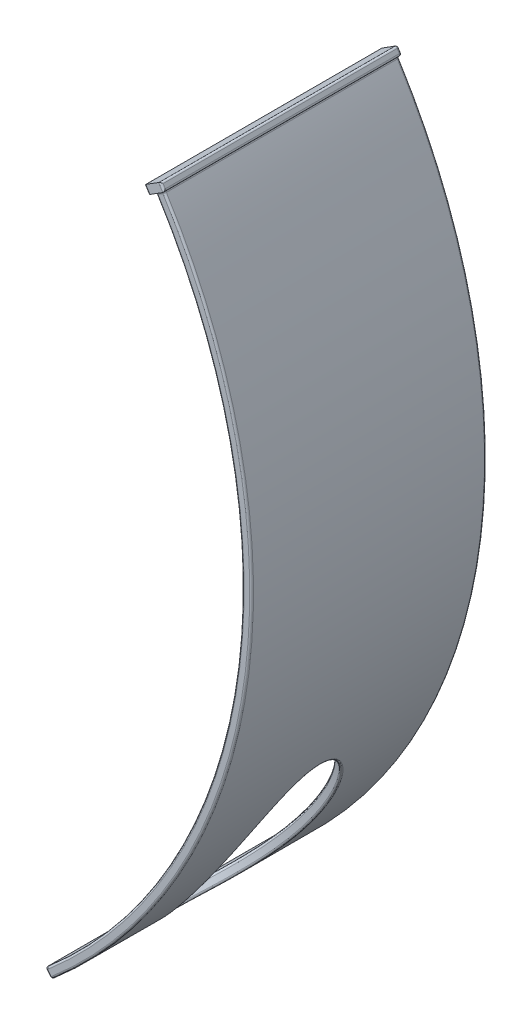
from build123d import *

# Parameters (mm, degrees)
SKETCH11_W              = 0.6
SKETCH11_H              = 15
SKETCH12_W              = 15
SKETCH12_H              = 0.6
BOSS_EXTRUDE1_DEPTH     = 0.2
SKETCH14_W              = 1.2
SKETCH14_H              = 15.2
BOSS_EXTRUDE2_DEPTH     = 0.5
SKETCH15_RX             = 7.50922571
SKETCH15_RY             = 3.403837019
CUT_EXTRUDE1_DEPTH      = 36.866449775
CUT_EXTRUDE1_DEPTH_BACK = 9.964201433
FILLET1_R               = 0.12


with BuildPart() as part:
    # Sweep1: sweep along a path in Sketch7
    with BuildLine(Plane.XY) as sweep1_path:
        ThreePointArc((12.832156868, 1.661937028), (17.974752885, -22.779601272), (5.915655903, -44.652261565))
    # Sketch11 → Sweep1 (sweep)
    with BuildSketch(Plane(origin=(0, -17.481848747, 0), x_dir=(1, 0, 0), z_dir=(0, 1, 0))):
        with Locations((18.66815125, 0)):
            Rectangle(SKETCH11_W, SKETCH11_H)
    sweep(path=sweep1_path.line)

    # Sketch12 → Boss-Extrude1 (add)
    with BuildSketch(Plane(origin=(-18.686960593, -16.10455616, 0), x_dir=(0, 0, 1), z_dir=(-0.757508036, -0.652825838, 0))):
        with Locations((0, -37.986339997)):
            Rectangle(SKETCH12_W, SKETCH12_H)
    extrude(amount=BOSS_EXTRUDE1_DEPTH)

    # Sketch14 → Boss-Extrude2 (add)
    with BuildSketch(Plane(origin=(2.905305624, -4.603278943, 0), x_dir=(0.845657103, 0.533726582, 0), z_dir=(-0.533726582, 0.845657103, 0))):
        with Locations((12.038624569, -0.1)):
            Rectangle(SKETCH14_W, SKETCH14_H)
    extrude(amount=BOSS_EXTRUDE2_DEPTH)

    # Sketch15 → Cut-Extrude1 (cut, two sides)
    with BuildSketch(Plane(origin=(24.602616496, -28.547705405, 0), x_dir=(0.757508036, 0.652825838, 0), z_dir=(-0.652825838, 0.757508036, 0))) as cut_extrude1_sk:
        with Locations(Location((-16.668993196, 0), (0, 0, 180))):
            Ellipse(SKETCH15_RX, SKETCH15_RY)
    extrude(amount=CUT_EXTRUDE1_DEPTH, mode=Mode.SUBTRACT)
    extrude(cut_extrude1_sk.sketch, amount=-CUT_EXTRUDE1_DEPTH_BACK, mode=Mode.SUBTRACT)

    # Fillet1
    fillet1_edges = [part.edges().sort_by_distance(p)[0] for p in [
        (17.974752885, -22.779601272, -7.5),
        (5.8399051, -44.717544149, -7.5),
        (6.231600603, -45.172048971, -7.5),
        (17.974752885, -22.779601272, 7.5),
        (6.231600603, -45.172048971, 7.5),
        (5.8399051, -44.717544149, 7.5),
        (5.960002048, -45.010079144, -7.5),
        (6.155849799, -45.237331555, 0),
        (5.960002048, -45.010079144, 7.5),
        (5.764154296, -44.782826733, 0),
        (18.568172144, -22.868221717, 7.5),
        (18.568172144, -22.868221717, -7.5),
        (13.59324826, 2.142290952, 0.1),
        (13.459816615, 2.353705228, 7.7),
        (13.466399695, 2.062231965, -7.5),
        (12.705308302, 1.581878041, -7.5),
        (13.459816615, 2.353705228, -7.5),
        (12.578459737, 1.501819054, 0.1),
        (12.445028091, 1.713233329, -7.5),
        (12.445028091, 1.713233329, 7.7),
        (13.326384969, 2.565119504, 0.1),
        (12.818990708, 2.244883554, -7.5),
        (12.311596446, 1.924647605, 0.1),
        (12.832156868, 1.661937028, 0),
        (13.085853999, 1.822055003, 7.5),
        (15.361887096, -31.856153967, -1e-09),
        (15.795472771, -32.359266149, -1e-09),
        (13.339551129, 1.982172977, 0),
    ]]
    fillet(fillet1_edges, radius=FILLET1_R)


solid = part.part
